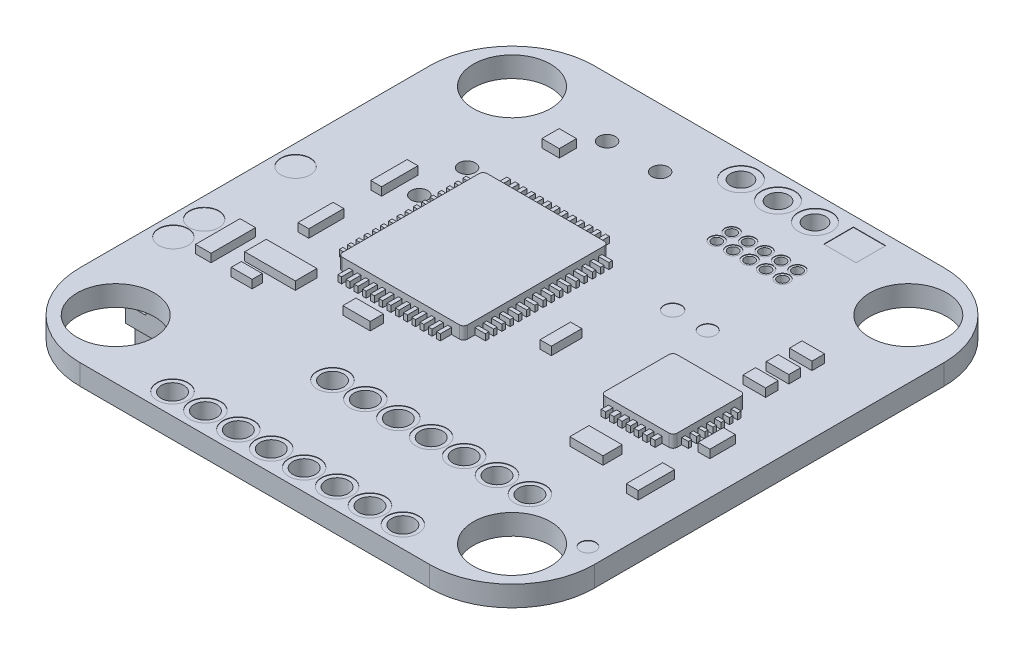
from build123d import *

# Parameters (mm, degrees)
SKETCH1_W           = 31.75
SKETCH1_H           = 31.75
BOSS_EXTRUDE1_DEPTH = 1.27
FILLET1_R           = 5.08
SKETCH2_R           = 2.38125
SKETCH2_R_2         = 0.513227476
CUT_EXTRUDE1_DEPTH  = 2540
SKETCH3_W           = 7.734024407
SKETCH3_H           = 8.94246572
SKETCH3_W_2         = 4.455512607
SKETCH3_H_2         = 4.44056294
BOSS_EXTRUDE2_DEPTH = 0.762
SKETCH4_W           = 0.665951654
SKETCH4_H           = 2.247586831
SKETCH4_H_2         = 2.164342875
SKETCH4_W_2         = 0.957305502
SKETCH4_H_3         = 2.747050572
SKETCH4_W_3         = 3.121648377
SKETCH4_H_4         = 1.331903307
SKETCH4_W_4         = 1.290281329
SKETCH4_H_5         = 0.624329675
SKETCH4_W_5         = 1.692581605
SKETCH4_H_6         = 0.81110746
SKETCH4_W_6         = 0.6963202
SKETCH4_H_7         = 1.884160541
SKETCH4_W_7         = 1.073669656
SKETCH4_H_8         = 1.064960306
SKETCH4_W_8         = 1.3926404
SKETCH4_H_9         = 0.778240224
SKETCH4_H_10        = 0.737280212
SKETCH4_W_9         = 2.048000588
SKETCH4_H_11        = 1.185705265
SKETCH4_W_10        = 0.737280212
SKETCH4_H_12        = 1.57031373
SKETCH4_H_13        = 2.247586832
BOSS_EXTRUDE3_DEPTH = 0.508
SKETCH5_W           = 0.913629892
SKETCH5_H           = 0.213828273
SKETCH5_H_2         = 0.213828272
SKETCH5_W_2         = 0.233267206
SKETCH5_H_3         = 1.069141363
SKETCH5_H_4         = 1.088580297
SKETCH5_W_3         = 0.819753322
SKETCH5_W_4         = 0.754173056
SKETCH5_H_5         = 0.210176866
SKETCH5_W_5         = 0.278716129
SKETCH5_H_6         = 0.676104487
SKETCH5_H_7         = 0.721819977
BOSS_EXTRUDE4_DEPTH = 0.381
SKETCH6_R           = 1.027987033
SKETCH6_R_2         = 0.426271727
SKETCH6_R_3         = 0.905059833
SKETCH6_R_4         = 0.504587533
SKETCH6_R_5         = 0.534547711
SKETCH6_R_6         = 0.478723023
SKETCH6_R_7         = 0.952228923
SKETCH6_W           = 1.997854961
SKETCH6_H           = 1.831367048
CUT_EXTRUDE2_DEPTH  = 0.0254
FILLET2_R           = 0.254
SKETCH7_W           = 14.734180338
SKETCH7_H           = 15.857973755
SKETCH7_W_2         = 4.578070361
SKETCH7_H_2         = 7.36709017
BOSS_EXTRUDE5_DEPTH = 1.905
SKETCH8_W           = 14.882958641
SKETCH8_H           = 1.379983815
CUT_EXTRUDE3_DEPTH  = 13.97
SKETCH10_W          = 6.798713526
SKETCH10_H          = 1.33450517
CUT_EXTRUDE4_DEPTH  = 3.81
CUT_EXTRUDE5_DEPTH  = 1.27
SKETCH12_W          = 3.03840442
SKETCH12_H          = 3.829222009
SKETCH12_H_2        = 3.995709922
CUT_EXTRUDE6_DEPTH  = 1.27
SKETCH13_W          = 1.664879134
SKETCH13_H          = 9.656298979
CUT_EXTRUDE7_DEPTH  = 0.239775
SKETCH14_W          = 1.415147264
SKETCH14_H          = 1.456769243
SKETCH14_H_2        = 1.623257156
SKETCH14_W_2        = 1.540013199
SKETCH14_H_3        = 0.832439567
SKETCH14_H_4        = 0.998927481
CUT_EXTRUDE8_DEPTH  = 1.27
BOSS_EXTRUDE6_DEPTH = 4.572
SKETCH16_W          = 0.680432362
SKETCH16_H          = 0.441361532
SKETCH16_W_2        = 0.643652234
SKETCH16_W_3        = 0.555541417
SKETCH16_W_4        = 0.604797181
CUT_EXTRUDE9_DEPTH  = 4.572
SKETCH17_W          = 0.555541417
SKETCH17_H          = 0.734843187
SKETCH17_W_2        = 0.604797181
CUT_EXTRUDE10_DEPTH = 3.048
SKETCH18_W          = 0.555541417
SKETCH18_H          = 0.712608625
SKETCH18_W_2        = 0.604797181
SKETCH18_H_2        = 1.628576262
CUT_EXTRUDE11_DEPTH = 1.27
SKETCH19_W          = 6.160052797
SKETCH19_H          = 2.78867255
BOSS_EXTRUDE7_DEPTH = 1.27
SKETCH20_W          = 2.081098918
SKETCH20_H          = 1.207037372
SKETCH20_W_2        = 2.830294529
SKETCH20_H_2        = 1.664879135
SKETCH20_W_3        = 0.624329675
SKETCH20_H_3        = 1.852178037
SKETCH20_W_4        = 0.665951653
SKETCH20_W_5        = 1.165415394
SKETCH20_H_4        = 0.790817589
SKETCH20_W_6        = 1.123615853
SKETCH20_H_5        = 0.653138375
SKETCH20_H_6        = 0.799491643
SKETCH20_H_7        = 0.752462723
SKETCH20_W_7        = 0.677623672
SKETCH20_H_8        = 1.387353146
SKETCH20_W_8        = 0.649208544
SKETCH20_W_9        = 2.205964853
SKETCH20_H_9        = 1.081665165
SKETCH20_W_10       = 0.58951107
SKETCH20_H_10       = 1.457896526
SKETCH20_W_11       = 0.681919343
SKETCH20_H_11       = 1.551954366
SKETCH20_W_12       = 1.222751924
SKETCH20_H_12       = 0.634890423
SKETCH20_H_13       = 0.705433802
BOSS_EXTRUDE8_DEPTH = 0.762
SKETCH21_R          = 0.698228923
SKETCH21_R_2        = 0.648998018
SKETCH21_R_3        = 0.301620328
CUT_EXTRUDE12_DEPTH = 16.002


with BuildPart() as part:
    # Sketch1 → Boss-Extrude1 (new body)
    with BuildSketch(Plane(origin=(0, 0, 0), x_dir=(1, 0, 0), z_dir=(0, 1, 0))):
        Rectangle(SKETCH1_W, SKETCH1_H)
    extrude(amount=BOSS_EXTRUDE1_DEPTH)

    # Fillet1
    fillet1_edges = [part.edges().sort_by_distance(p)[0] for p in [
        (-15.875, 0.635, -15.875),
        (15.875, 0.635, -15.875),
        (15.875, 0.635, 15.875),
        (-15.875, 0.635, 15.875),
    ]]
    fillet(fillet1_edges, radius=FILLET1_R)

    # Sketch2 → Cut-Extrude1 (cut)
    with BuildSketch(Plane(origin=(0, 1.27, 0), x_dir=(1, 0, 0), z_dir=(0, 1, 0))):
        with Locations((12.235378749, 12.235378749)):
            Circle(SKETCH2_R)
        with Locations((-12.235378749, 12.235378749)):
            Circle(SKETCH2_R)
        with Locations((-12.235378749, -12.235378749)):
            Circle(SKETCH2_R)
        with Locations((12.235378749, -12.235378749)):
            Circle(SKETCH2_R)
        with Locations((-6.365121013, 12.235378749)):
            Circle(SKETCH2_R_2)
        with Locations((-3.088320071, 12.235378749)):
            Circle(SKETCH2_R_2)
        with Locations((-9.273281849, 6.498808589)):
            Circle(SKETCH2_R_2)
        with Locations((-9.273281849, 3.549687741)):
            Circle(SKETCH2_R_2)
    extrude(amount=-CUT_EXTRUDE1_DEPTH, mode=Mode.SUBTRACT)

    # Sketch3 → Boss-Extrude2 (add)
    with BuildSketch(Plane(origin=(0, 1.27, 0), x_dir=(1, 0, 0), z_dir=(0, 1, 0))):
        with Locations((-3.955858025, 1.568424552)):
            Rectangle(SKETCH3_W, SKETCH3_H)
        with Locations((9.941217082, 0)):
            Rectangle(SKETCH3_W_2, SKETCH3_H_2)
    extrude(amount=BOSS_EXTRUDE2_DEPTH)

    # Sketch4 → Boss-Extrude3 (add)
    with BuildSketch(Plane(origin=(0, 1.27, 0), x_dir=(1, 0, 0), z_dir=(0, 1, 0))):
        with Locations((-10.717659427, 3.454624204)):
            Rectangle(SKETCH4_W, SKETCH4_H)
        with Locations((-10.717659427, -1.082171437)):
            Rectangle(SKETCH4_W, SKETCH4_H_2)
        with Locations((-12.569837464, -5.119503338)):
            Rectangle(SKETCH4_W_2, SKETCH4_H_3)
        with Locations((-9.573055023, -4.703283555)):
            Rectangle(SKETCH4_W_3, SKETCH4_H_4)
        with Locations((-10.072518762, -6.305729722)):
            Rectangle(SKETCH4_W_4, SKETCH4_H_5)
        with Locations((-4.377267482, -4.817483436)):
            Rectangle(SKETCH4_W_5, SKETCH4_H_6)
        with Locations((3.035201688, -0.013833282)):
            Rectangle(SKETCH4_W_6, SKETCH4_H_7)
        with Locations((-7.475396006, 10.390009707)):
            Rectangle(SKETCH4_W_7, SKETCH4_H_8)
        with Locations((11.53440413, 6.683128642)):
            Rectangle(SKETCH4_W_8, SKETCH4_H_9)
        with Locations((11.53440413, 5.229048224)):
            Rectangle(SKETCH4_W_8, SKETCH4_H_10)
        with Locations((11.53440413, 3.815927818)):
            Rectangle(SKETCH4_W_8, SKETCH4_H_9)
        with Locations((9.814083636, -4.630184533)):
            Rectangle(SKETCH4_W_9, SKETCH4_H_11)
        with Locations((13.418564672, -0.785156865)):
            Rectangle(SKETCH4_W_10, SKETCH4_H_12)
        with Locations((13.418564672, -4.869771468)):
            Rectangle(SKETCH4_W_10, SKETCH4_H_13)
    extrude(amount=BOSS_EXTRUDE3_DEPTH)

    # Sketch5 → Boss-Extrude4 (add)
    with BuildSketch(Plane(origin=(0, 1.27, 0), x_dir=(1, 0, 0), z_dir=(0, 1, 0))):
        with Locations((0.099544847, 5.02121391)):
            Rectangle(SKETCH5_W, SKETCH5_H)
        with Locations((0.099544847, 5.529205613)):
            Rectangle(SKETCH5_W, SKETCH5_H_2)
        with Locations((-8.006490575, 5.529205613)):
            Rectangle(SKETCH5_W, SKETCH5_H_2)
        with Locations((-8.006490575, 5.02121391)):
            Rectangle(SKETCH5_W, SKETCH5_H)
        with Locations((0.099544847, 4.513222205)):
            Rectangle(SKETCH5_W, SKETCH5_H)
        with Locations((-8.006490575, 4.513222205)):
            Rectangle(SKETCH5_W, SKETCH5_H)
        with Locations((0.099544847, 4.005230501)):
            Rectangle(SKETCH5_W, SKETCH5_H)
        with Locations((-8.006490575, 4.005230501)):
            Rectangle(SKETCH5_W, SKETCH5_H)
        with Locations((0.099544847, 3.497238798)):
            Rectangle(SKETCH5_W, SKETCH5_H_2)
        with Locations((-8.006490575, 3.497238798)):
            Rectangle(SKETCH5_W, SKETCH5_H_2)
        with Locations((0.099544847, 2.989247095)):
            Rectangle(SKETCH5_W, SKETCH5_H)
        with Locations((-8.006490575, 2.989247095)):
            Rectangle(SKETCH5_W, SKETCH5_H)
        with Locations((0.099544847, 2.481255391)):
            Rectangle(SKETCH5_W, SKETCH5_H)
        with Locations((-8.006490575, 2.481255391)):
            Rectangle(SKETCH5_W, SKETCH5_H)
        with Locations((0.099544847, 1.973263687)):
            Rectangle(SKETCH5_W, SKETCH5_H)
        with Locations((-8.006490575, 1.973263687)):
            Rectangle(SKETCH5_W, SKETCH5_H)
        with Locations((0.099544847, 1.465271983)):
            Rectangle(SKETCH5_W, SKETCH5_H_2)
        with Locations((-8.006490575, 1.465271983)):
            Rectangle(SKETCH5_W, SKETCH5_H_2)
        with Locations((0.099544847, 0.957280279)):
            Rectangle(SKETCH5_W, SKETCH5_H_2)
        with Locations((-8.006490575, 0.957280279)):
            Rectangle(SKETCH5_W, SKETCH5_H_2)
        with Locations((0.099544847, 0.449288576)):
            Rectangle(SKETCH5_W, SKETCH5_H)
        with Locations((-8.006490575, 0.449288576)):
            Rectangle(SKETCH5_W, SKETCH5_H)
        with Locations((0.099544847, -0.058703129)):
            Rectangle(SKETCH5_W, SKETCH5_H)
        with Locations((-8.006490575, -0.058703129)):
            Rectangle(SKETCH5_W, SKETCH5_H)
        with Locations((0.099544847, -0.566694832)):
            Rectangle(SKETCH5_W, SKETCH5_H_2)
        with Locations((-8.006490575, -0.566694832)):
            Rectangle(SKETCH5_W, SKETCH5_H_2)
        with Locations((0.099544847, -1.074686536)):
            Rectangle(SKETCH5_W, SKETCH5_H_2)
        with Locations((-8.006490575, -1.074686536)):
            Rectangle(SKETCH5_W, SKETCH5_H_2)
        with Locations((0.099544847, -1.58267824)):
            Rectangle(SKETCH5_W, SKETCH5_H)
        with Locations((-8.006490575, -1.58267824)):
            Rectangle(SKETCH5_W, SKETCH5_H)
        with Locations((0.099544847, -2.090669944)):
            Rectangle(SKETCH5_W, SKETCH5_H)
        with Locations((-8.006490575, -2.090669944)):
            Rectangle(SKETCH5_W, SKETCH5_H)
        with Locations((-6.536263349, 6.306762968)):
            Rectangle(SKETCH5_W_2, SKETCH5_H_3)
        with Locations((-7.044263349, 6.306762968)):
            Rectangle(SKETCH5_W_2, SKETCH5_H_3)
        with Locations((-7.044263349, -3.05308369)):
            Rectangle(SKETCH5_W_2, SKETCH5_H_4)
        with Locations((-6.536263349, -3.05308369)):
            Rectangle(SKETCH5_W_2, SKETCH5_H_4)
        with Locations((-6.028263349, 6.306762968)):
            Rectangle(SKETCH5_W_2, SKETCH5_H_3)
        with Locations((-6.028263349, -3.05308369)):
            Rectangle(SKETCH5_W_2, SKETCH5_H_4)
        with Locations((-5.520263349, 6.306762968)):
            Rectangle(SKETCH5_W_2, SKETCH5_H_3)
        with Locations((-5.520263349, -3.05308369)):
            Rectangle(SKETCH5_W_2, SKETCH5_H_4)
        with Locations((-5.012263349, 6.306762968)):
            Rectangle(SKETCH5_W_2, SKETCH5_H_3)
        with Locations((-5.012263349, -3.05308369)):
            Rectangle(SKETCH5_W_2, SKETCH5_H_4)
        with Locations((-4.504263349, 6.306762968)):
            Rectangle(SKETCH5_W_2, SKETCH5_H_3)
        with Locations((-4.504263349, -3.05308369)):
            Rectangle(SKETCH5_W_2, SKETCH5_H_4)
        with Locations((-3.996263349, 6.306762968)):
            Rectangle(SKETCH5_W_2, SKETCH5_H_3)
        with Locations((-3.996263349, -3.05308369)):
            Rectangle(SKETCH5_W_2, SKETCH5_H_4)
        with Locations((-3.488263349, 6.306762968)):
            Rectangle(SKETCH5_W_2, SKETCH5_H_3)
        with Locations((-3.488263349, -3.05308369)):
            Rectangle(SKETCH5_W_2, SKETCH5_H_4)
        with Locations((-2.980263349, 6.306762968)):
            Rectangle(SKETCH5_W_2, SKETCH5_H_3)
        with Locations((-2.980263349, -3.05308369)):
            Rectangle(SKETCH5_W_2, SKETCH5_H_4)
        with Locations((-2.472263349, 6.306762968)):
            Rectangle(SKETCH5_W_2, SKETCH5_H_3)
        with Locations((-2.472263349, -3.05308369)):
            Rectangle(SKETCH5_W_2, SKETCH5_H_4)
        with Locations((-1.964263349, 6.306762968)):
            Rectangle(SKETCH5_W_2, SKETCH5_H_3)
        with Locations((-1.964263349, -3.05308369)):
            Rectangle(SKETCH5_W_2, SKETCH5_H_4)
        with Locations((-1.456263349, 6.306762968)):
            Rectangle(SKETCH5_W_2, SKETCH5_H_3)
        with Locations((-1.456263349, -3.05308369)):
            Rectangle(SKETCH5_W_2, SKETCH5_H_4)
        with Locations((-0.948263349, 6.306762968)):
            Rectangle(SKETCH5_W_2, SKETCH5_H_3)
        with Locations((-0.948263349, -3.05308369)):
            Rectangle(SKETCH5_W_2, SKETCH5_H_4)
        with Locations((7.755699681, -1.07467824)):
            Rectangle(SKETCH5_W_3, SKETCH5_H)
        with Locations((7.755699681, -1.58267824)):
            Rectangle(SKETCH5_W_3, SKETCH5_H)
        with Locations((12.198762686, -1.584503943)):
            Rectangle(SKETCH5_W_4, SKETCH5_H_5)
        with Locations((12.198762686, -1.076503943)):
            Rectangle(SKETCH5_W_4, SKETCH5_H_5)
        with Locations((7.755699681, -0.56667824)):
            Rectangle(SKETCH5_W_3, SKETCH5_H)
        with Locations((12.198762686, -0.568503943)):
            Rectangle(SKETCH5_W_4, SKETCH5_H_5)
        with Locations((7.755699681, -0.05867824)):
            Rectangle(SKETCH5_W_3, SKETCH5_H)
        with Locations((12.198762686, -0.060503943)):
            Rectangle(SKETCH5_W_4, SKETCH5_H_5)
        with Locations((7.755699681, 0.449321761)):
            Rectangle(SKETCH5_W_3, SKETCH5_H)
        with Locations((12.198762686, 0.447496057)):
            Rectangle(SKETCH5_W_4, SKETCH5_H_5)
        with Locations((7.755699681, 0.957321761)):
            Rectangle(SKETCH5_W_3, SKETCH5_H)
        with Locations((12.198762686, 0.955496057)):
            Rectangle(SKETCH5_W_4, SKETCH5_H_5)
        with Locations((7.755699681, 1.465321761)):
            Rectangle(SKETCH5_W_3, SKETCH5_H)
        with Locations((12.198762686, 1.463496057)):
            Rectangle(SKETCH5_W_4, SKETCH5_H_5)
        with Locations((8.812934407, -2.321808051)):
            Rectangle(SKETCH5_W_5, SKETCH5_H_6)
        with Locations((8.304934407, 2.227259539)):
            Rectangle(SKETCH5_W_5, SKETCH5_H_7)
        with Locations((8.304934407, -2.321808051)):
            Rectangle(SKETCH5_W_5, SKETCH5_H_6)
        with Locations((8.812934407, 2.227259539)):
            Rectangle(SKETCH5_W_5, SKETCH5_H_7)
        with Locations((9.320934407, -2.321808051)):
            Rectangle(SKETCH5_W_5, SKETCH5_H_6)
        with Locations((9.320934407, 2.227259539)):
            Rectangle(SKETCH5_W_5, SKETCH5_H_7)
        with Locations((9.828934407, -2.321808051)):
            Rectangle(SKETCH5_W_5, SKETCH5_H_6)
        with Locations((9.828934407, 2.227259539)):
            Rectangle(SKETCH5_W_5, SKETCH5_H_7)
        with Locations((10.336934407, -2.321808051)):
            Rectangle(SKETCH5_W_5, SKETCH5_H_6)
        with Locations((10.336934407, 2.227259539)):
            Rectangle(SKETCH5_W_5, SKETCH5_H_7)
        with Locations((10.844934407, -2.321808051)):
            Rectangle(SKETCH5_W_5, SKETCH5_H_6)
        with Locations((10.844934407, 2.227259539)):
            Rectangle(SKETCH5_W_5, SKETCH5_H_7)
        with Locations((11.352934407, -2.321808051)):
            Rectangle(SKETCH5_W_5, SKETCH5_H_6)
        with Locations((11.352934407, 2.227259539)):
            Rectangle(SKETCH5_W_5, SKETCH5_H_7)
    extrude(amount=BOSS_EXTRUDE4_DEPTH)

    # Sketch6 → Cut-Extrude2 (cut)
    with BuildSketch(Plane(origin=(0, 1.27, 0), x_dir=(1, 0, 0), z_dir=(0, 1, 0))):
        with Locations((4.370307728, 14.338771544)):
            Circle(SKETCH6_R)
        with Locations((2.084307728, 14.338771544)):
            Circle(SKETCH6_R)
        with Locations((-0.201692272, 14.338771544)):
            Circle(SKETCH6_R)
        with Locations((6.409784667, 11.217123168)):
            Circle(SKETCH6_R_2)
        with Locations((6.409784667, 10.293398218)):
            Circle(SKETCH6_R_2)
        with Locations((5.393784667, 11.217123168)):
            Circle(SKETCH6_R_2)
        with Locations((5.393784667, 10.293398218)):
            Circle(SKETCH6_R_2)
        with Locations((4.377784667, 11.217123168)):
            Circle(SKETCH6_R_2)
        with Locations((4.377784667, 10.293398218)):
            Circle(SKETCH6_R_2)
        with Locations((3.361784667, 11.217123168)):
            Circle(SKETCH6_R_2)
        with Locations((3.361784667, 10.293398218)):
            Circle(SKETCH6_R_2)
        with Locations((2.345784667, 11.217123168)):
            Circle(SKETCH6_R_2)
        with Locations((2.345784667, 10.293398218)):
            Circle(SKETCH6_R_2)
        with Locations((-14.634699345, 1.269473008)):
            Circle(SKETCH6_R_3)
        with Locations((-14.634699345, -4.375397019)):
            Circle(SKETCH6_R_3)
        with Locations((-14.634699345, -6.273101018)):
            Circle(SKETCH6_R_3)
        with Locations((6.855725392, 5.229884908)):
            Circle(SKETCH6_R_4)
        with Locations((4.691431935, 5.229884908)):
            Circle(SKETCH6_R_5)
        with Locations((14.725883417, -10.038221661)):
            Circle(SKETCH6_R_6)
        with Locations((10.121840972, -9.015101117)):
            Circle(SKETCH6_R_7)
        with Locations((8.089840972, -9.015101117)):
            Circle(SKETCH6_R_7)
        with Locations((6.057840972, -9.015101117)):
            Circle(SKETCH6_R_7)
        with Locations((4.025840972, -9.015101117)):
            Circle(SKETCH6_R_7)
        with Locations((1.993840972, -9.015101117)):
            Circle(SKETCH6_R_7)
        with Locations((-0.038159028, -9.015101117)):
            Circle(SKETCH6_R_7)
        with Locations((-2.070159028, -9.015101117)):
            Circle(SKETCH6_R_7)
        with Locations((7.824931931, -14.563562525)):
            Circle(SKETCH6_R_7)
        with Locations((5.792931931, -14.563562525)):
            Circle(SKETCH6_R_7)
        with Locations((3.760931931, -14.563562525)):
            Circle(SKETCH6_R_7)
        with Locations((1.728931931, -14.563562525)):
            Circle(SKETCH6_R_7)
        with Locations((-0.303068069, -14.563562525)):
            Circle(SKETCH6_R_7)
        with Locations((-2.335068069, -14.563562525)):
            Circle(SKETCH6_R_7)
        with Locations((-4.367068069, -14.563562525)):
            Circle(SKETCH6_R_7)
        with Locations((-6.399068069, -14.563562525)):
            Circle(SKETCH6_R_7)
        with Locations((6.826004451, 14.338771544)):
            Rectangle(SKETCH6_W, SKETCH6_H)
    extrude(amount=-CUT_EXTRUDE2_DEPTH, mode=Mode.SUBTRACT)

    # Fillet2
    fillet2_edges = [part.edges().sort_by_distance(p)[0] for p in [
        (-7.822870229, 1.651, -6.039657412),
        (-7.822870229, 1.651, 2.902808308),
        (-0.088845822, 1.651, 2.902808308),
        (-0.088845822, 1.651, -6.039657412),
        (7.713460778, 1.651, -2.22028147),
        (7.713460778, 1.651, 2.22028147),
        (12.168973385, 1.651, 2.22028147),
        (12.168973385, 1.651, -2.22028147),
    ]]
    fillet(fillet2_edges, radius=FILLET2_R)

    # Sketch7 → Boss-Extrude5 (add)
    with BuildSketch(Plane.XZ):
        with Locations((5.223558284, -0.853250556)):
            Rectangle(SKETCH7_W, SKETCH7_H)
        with Locations((-13.089938565, -5.098692349)):
            Rectangle(SKETCH7_W_2, SKETCH7_H_2)
    extrude(amount=BOSS_EXTRUDE5_DEPTH)

    # Sketch8 → Cut-Extrude3 (cut)
    with BuildSketch(Plane(origin=(12.590648453, 0, 0), x_dir=(0, 0, -1), z_dir=(1, 0, 0))):
        with Locations((0.833352515, -0.929767195)):
            Rectangle(SKETCH8_W, SKETCH8_H)
    extrude(amount=-CUT_EXTRUDE3_DEPTH, mode=Mode.SUBTRACT)

    # Sketch10 → Cut-Extrude4 (cut)
    with BuildSketch(Plane.ZY.offset(15.378973745)):
        with Locations((-5.097593598, -0.899949488)):
            Rectangle(SKETCH10_W, SKETCH10_H)
    extrude(amount=-CUT_EXTRUDE4_DEPTH, mode=Mode.SUBTRACT)

    # Sketch11 → Cut-Extrude5 (cut)
    with BuildSketch(Plane.XZ.offset(1.905)):
        Polygon((12.590648453, 3.973420502), (7.75794531, 1.103415111), (7.75794531, -5.717764563), (12.590648453, -7.603711228), align=None)
    extrude(amount=-CUT_EXTRUDE5_DEPTH, mode=Mode.SUBTRACT)

    # Sketch12 → Cut-Extrude6 (cut)
    with BuildSketch(Plane.XZ.offset(0.239775287)):
        with Locations((4.953015425, -1.373525285)):
            Rectangle(SKETCH12_W, SKETCH12_H)
        with Locations((4.953015425, -5.82707697)):
            Rectangle(SKETCH12_W, SKETCH12_H_2)
    extrude(amount=-CUT_EXTRUDE6_DEPTH, mode=Mode.SUBTRACT)

    # Sketch13 → Cut-Extrude7 (cut)
    with BuildSketch(Plane.XZ.offset(0.239775287)):
        with Locations((11.758208886, -2.830294529)):
            Rectangle(SKETCH13_W, SKETCH13_H)
    extrude(amount=-CUT_EXTRUDE7_DEPTH, mode=Mode.SUBTRACT)

    # Sketch14 → Cut-Extrude8 (cut)
    with BuildSketch(Plane.XZ.offset(1.905)):
        with Locations((-11.508477016, -3.433813214)):
            Rectangle(SKETCH14_W, SKETCH14_H)
        with Locations((-11.508477016, -7.013303353)):
            Rectangle(SKETCH14_W, SKETCH14_H_2)
        with Locations((-14.109850664, -2.705428594)):
            Rectangle(SKETCH14_W_2, SKETCH14_H_3)
        with Locations((-14.109850664, -7.61682204)):
            Rectangle(SKETCH14_W_2, SKETCH14_H_4)
    extrude(amount=-CUT_EXTRUDE8_DEPTH, mode=Mode.SUBTRACT)

    # Sketch15 → Boss-Extrude6 (add)
    with BuildSketch(Plane(origin=(0, 0, 0), x_dir=(-1, 0, 0), z_dir=(0, -1, 0))):
        Polygon((9.302512163, -1.706501113), (9.302512163, -0.964616609), (15.461197982, -0.964616609), (15.461197982, -8.414357038), (9.302512163, -8.414357038), (9.302512163, -7.700065996), (10.884147341, -7.700065996), (10.884147341, -1.706501113), align=None)
    extrude(amount=BOSS_EXTRUDE6_DEPTH)

    # Sketch16 → Cut-Extrude9 (cut)
    with BuildSketch(Plane.ZY.offset(15.461197982)):
        Polygon((5.23495092, -3.826913807), (7.461685575, -3.826913807), (7.461685575, -0.867969527), (1.994071145, -0.867969527), (1.994071145, -3.826913807), (4.149937154, -3.826913807), (4.149937154, -4.264732145), (5.23495092, -4.264732145), align=None)
        with Locations((3.276409122, -2.903867422)):
            Rectangle(SKETCH16_W, SKETCH16_H, mode=Mode.SUBTRACT)
        with Locations((6.200429272, -2.903867422)):
            Rectangle(SKETCH16_W_2, SKETCH16_H, mode=Mode.SUBTRACT)
        with Locations((1.242387317, -2.903867422)):
            Rectangle(SKETCH16_W_3, SKETCH16_H)
        with Locations((8.111958448, -2.903867422)):
            Rectangle(SKETCH16_W_4, SKETCH16_H)
    extrude(amount=-CUT_EXTRUDE9_DEPTH, mode=Mode.SUBTRACT)

    # Sketch17 → Cut-Extrude10 (cut)
    with BuildSketch(Plane.ZY.offset(15.461197982)):
        with Locations((1.242387317, -3.491969782)):
            Rectangle(SKETCH17_W, SKETCH17_H)
        with Locations((8.111958448, -3.491969782)):
            Rectangle(SKETCH17_W_2, SKETCH17_H)
    extrude(amount=-CUT_EXTRUDE10_DEPTH, mode=Mode.SUBTRACT)

    # Sketch18 → Cut-Extrude11 (cut)
    with BuildSketch(Plane.ZY.offset(15.461197982)):
        with Locations((1.242387317, -4.215695688)):
            Rectangle(SKETCH18_W, SKETCH18_H)
        with Locations((8.111958448, -4.215695688)):
            Rectangle(SKETCH18_W_2, SKETCH18_H)
        with Locations((1.242387317, -0.814288131)):
            Rectangle(SKETCH18_W, SKETCH18_H_2)
        with Locations((8.111958448, -0.814288131)):
            Rectangle(SKETCH18_W_2, SKETCH18_H_2)
    extrude(amount=-CUT_EXTRUDE11_DEPTH, mode=Mode.SUBTRACT)

    # Sketch19 → Boss-Extrude7 (add)
    with BuildSketch(Plane(origin=(0, 0, 0), x_dir=(-1, 0, 0), z_dir=(0, -1, 0))):
        with Locations((4.640850587, 12.049562735)):
            Rectangle(SKETCH19_W, SKETCH19_H)
    extrude(amount=BOSS_EXTRUDE7_DEPTH)

    # Sketch20 → Boss-Extrude8 (add)
    with BuildSketch(Plane(origin=(0, 0, 0), x_dir=(-1, 0, 0), z_dir=(0, -1, 0))):
        with Locations((7.013303353, 6.055997851)):
            Rectangle(SKETCH20_W, SKETCH20_H)
        with Locations((5.181936306, 2.497318702)):
            Rectangle(SKETCH20_W_2, SKETCH20_H_2)
        with Locations((4.57841762, 6.98208687)):
            Rectangle(SKETCH20_W_3, SKETCH20_H_3)
        with Locations((3.433813215, 6.98208687)):
            Rectangle(SKETCH20_W_4, SKETCH20_H_3)
        with Locations((3.683545085, 9.260890185)):
            Rectangle(SKETCH20_W_5, SKETCH20_H_4)
        with Locations((9.614765783, 0.131272575)):
            Rectangle(SKETCH20_W_6, SKETCH20_H_5)
        with Locations((9.469000077, -3.837607083)):
            Rectangle(SKETCH20_W_2, SKETCH20_H_6)
        with Locations((9.469000077, -5.483619289)):
            Rectangle(SKETCH20_W_2, SKETCH20_H_7)
        with Locations((5.229394293, -1.215744783)):
            Rectangle(SKETCH20_W_7, SKETCH20_H_8)
        with Locations((4.091393313, -1.215744783)):
            Rectangle(SKETCH20_W_8, SKETCH20_H_8)
        with Locations((4.869771468, -3.978693844)):
            Rectangle(SKETCH20_W_9, SKETCH20_H_9)
        with Locations((2.806081853, -4.166809524)):
            Rectangle(SKETCH20_W_10, SKETCH20_H_10)
        with Locations((5.909165801, -8.21129666)):
            Rectangle(SKETCH20_W_11, SKETCH20_H_11)
        with Locations((7.825594298, -9.704464876)):
            Rectangle(SKETCH20_W_12, SKETCH20_H_12)
        with Locations((7.825594298, -10.656800509)):
            Rectangle(SKETCH20_W_12, SKETCH20_H_13)
    extrude(amount=BOSS_EXTRUDE8_DEPTH)

    # Sketch21 → Cut-Extrude12 (cut)
    with BuildSketch(Plane(origin=(0, 1.2446, 0), x_dir=(1, 0, 0), z_dir=(0, 1, 0))):
        with Locations((-6.399068069, -14.563562525)):
            Circle(SKETCH21_R)
        with Locations((-4.367068069, -14.563562525)):
            Circle(SKETCH21_R)
        with Locations((-0.303068069, -14.563562525)):
            Circle(SKETCH21_R)
        with Locations((-2.335068069, -14.563562525)):
            Circle(SKETCH21_R)
        with Locations((1.728931931, -14.563562525)):
            Circle(SKETCH21_R)
        with Locations((3.760931931, -14.563562525)):
            Circle(SKETCH21_R)
        with Locations((5.792931931, -14.563562525)):
            Circle(SKETCH21_R)
        with Locations((7.824931931, -14.563562525)):
            Circle(SKETCH21_R)
        with Locations((-0.038159028, -9.015101117)):
            Circle(SKETCH21_R)
        with Locations((-2.070159028, -9.015101117)):
            Circle(SKETCH21_R)
        with Locations((1.993840972, -9.015101117)):
            Circle(SKETCH21_R)
        with Locations((4.025840972, -9.015101117)):
            Circle(SKETCH21_R)
        with Locations((6.057840972, -9.015101117)):
            Circle(SKETCH21_R)
        with Locations((8.089840972, -9.015101117)):
            Circle(SKETCH21_R)
        with Locations((10.121840972, -9.015101117)):
            Circle(SKETCH21_R)
        with Locations((4.370307728, 14.338771544)):
            Circle(SKETCH21_R_2)
        with Locations((2.084307728, 14.338771544)):
            Circle(SKETCH21_R_2)
        with Locations((-0.201692272, 14.338771544)):
            Circle(SKETCH21_R_2)
        with Locations((6.409784667, 11.217123168)):
            Circle(SKETCH21_R_3)
        with Locations((6.409784667, 10.293398218)):
            Circle(SKETCH21_R_3)
        with Locations((5.393784667, 11.217123168)):
            Circle(SKETCH21_R_3)
        with Locations((5.393784667, 10.293398218)):
            Circle(SKETCH21_R_3)
        with Locations((4.377784667, 11.217123168)):
            Circle(SKETCH21_R_3)
        with Locations((4.377784667, 10.293398218)):
            Circle(SKETCH21_R_3)
        with Locations((3.361784667, 11.217123168)):
            Circle(SKETCH21_R_3)
        with Locations((3.361784667, 10.293398218)):
            Circle(SKETCH21_R_3)
        with Locations((2.345784667, 11.217123168)):
            Circle(SKETCH21_R_3)
        with Locations((2.345784667, 10.293398218)):
            Circle(SKETCH21_R_3)
    extrude(amount=-CUT_EXTRUDE12_DEPTH, mode=Mode.SUBTRACT)


solid = part.part
